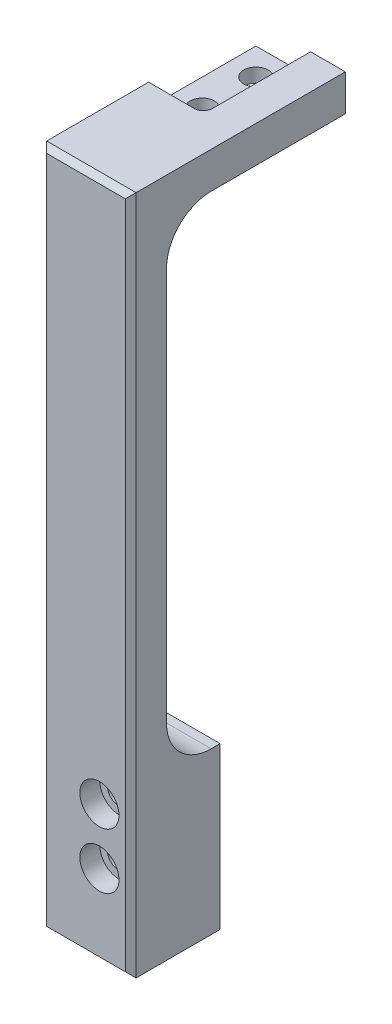
from build123d import *

# Parameters (mm, degrees)
SKETCH1_W                                      = 12.7
SKETCH1_H                                      = 96.5962
EXTRUDE1_DEPTH                                 = 5.08
SKETCH2_W                                      = 12.7
SKETCH2_H                                      = 5.16498089
EXTRUDE2_DEPTH                                 = 25.4
F_4_CLEARANCE_HOLE1_D                          = 3.4544
SKETCH6_W                                      = 12.7
SKETCH6_H                                      = 22.86
EXTRUDE4_DEPTH                                 = 7.62
SKETCH7_W                                      = 7.9248
SKETCH7_H                                      = 15.24
EXTRUDE5_DEPTH                                 = 3.175
FILLET1_R                                      = 1.27
FILLET3_R                                      = 6.35
CHAMFER1_SIZE                                  = 0.762
CBORE_FOR_4_SOCKET_HEAD_CAP_SCREW1_D           = 3.4544
CBORE_FOR_4_SOCKET_HEAD_CAP_SCREW1_CBORE_D     = 5.55752
CBORE_FOR_4_SOCKET_HEAD_CAP_SCREW1_CBORE_DEPTH = 2.8448


with BuildPart() as part:
    # Sketch1 → Extrude1 (new body)
    with BuildSketch(Plane.XY):
        with Locations((6.35, -48.2981)):
            Rectangle(SKETCH1_W, SKETCH1_H)
    extrude(amount=EXTRUDE1_DEPTH)

    # Sketch2 → Extrude2 (add)
    with BuildSketch(Plane(origin=(0, 0, 0), x_dir=(-1, 0, 0), z_dir=(0, 0, -1))):
        with Locations((-6.35, -2.582490445)):
            Rectangle(SKETCH2_W, SKETCH2_H)
    extrude(amount=EXTRUDE2_DEPTH)

    # #4 Clearance Hole1 (through all)
    with Locations(Plane(origin=(0, 0, 0), x_dir=(-1, 0, 0), z_dir=(0, 1, 0))):
        with Locations((-3.81, -21.59), (-3.81, -13.97)):
            Hole(F_4_CLEARANCE_HOLE1_D / 2)

    # Sketch6 → Extrude4 (add)
    with BuildSketch(Plane(origin=(0, 0, 0), x_dir=(-1, 0, 0), z_dir=(0, 0, -1))):
        with Locations((-6.35, -85.1662)):
            Rectangle(SKETCH6_W, SKETCH6_H)
    extrude(amount=EXTRUDE4_DEPTH)

    # Sketch7 → Extrude5 (cut)
    with BuildSketch(Plane(origin=(0, 0, 0), x_dir=(1, 0, 0), z_dir=(0, 1, 0))):
        with Locations((3.81, 17.78)):
            Rectangle(SKETCH7_W, SKETCH7_H)
    extrude(amount=-EXTRUDE5_DEPTH, mode=Mode.SUBTRACT)

    # Fillet1
    fillet1_edges = [part.edges().sort_by_distance(p)[0] for p in [
        (7.7724, -1.5875, -10.16),
    ]]
    fillet(fillet1_edges, radius=FILLET1_R)

    # Fillet3
    fillet3_edges = [part.edges().sort_by_distance(p)[0] for p in [
        (6.35, -5.16498089, 0),
        (6.35, -73.7362, 0),
    ]]
    fillet(fillet3_edges, radius=FILLET3_R)

    # Chamfer1
    chamfer1_edges = [part.edges().sort_by_distance(p)[0] for p in [
        (12.7, -48.2981, 5.08),
        (6.35, 0, 5.08),
        (0, -48.2981, 5.08),
        (6.35, -96.5962, 5.08),
    ]]
    chamfer(chamfer1_edges, length=CHAMFER1_SIZE)

    # CBORE for #4 Socket Head Cap Screw1 (through all)
    with Locations(Plane.XY.offset(5.08)):
        with Locations((8.255, -84.97178089), (8.255, -77.04698089)):
            CounterBoreHole(CBORE_FOR_4_SOCKET_HEAD_CAP_SCREW1_D / 2, CBORE_FOR_4_SOCKET_HEAD_CAP_SCREW1_CBORE_D / 2, CBORE_FOR_4_SOCKET_HEAD_CAP_SCREW1_CBORE_DEPTH)


solid = part.part
